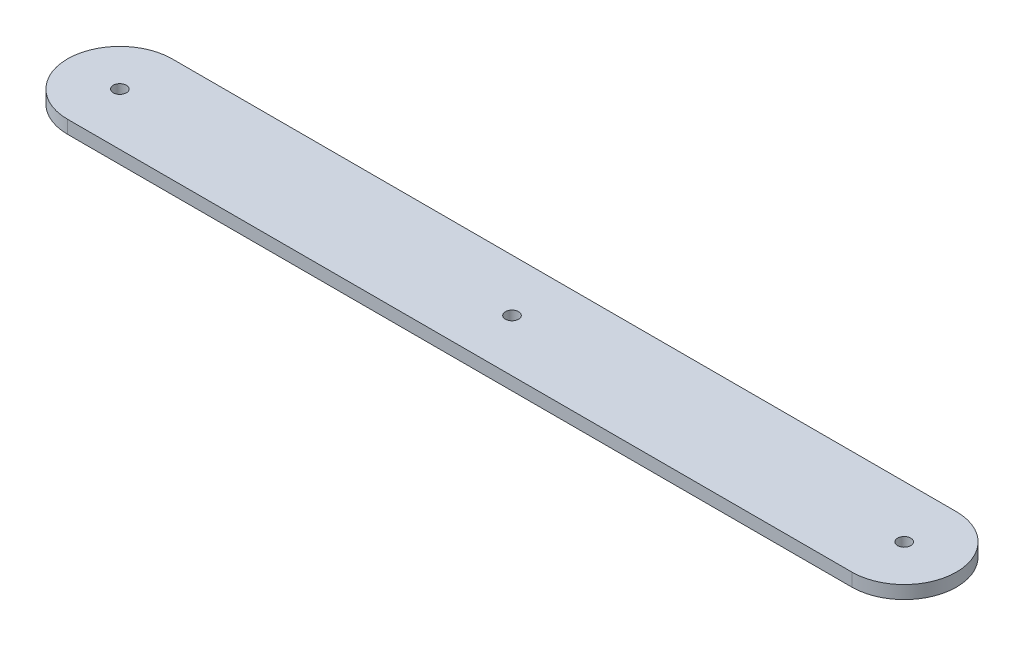
from build123d import *

# Parameters (mm, degrees)
BOSS_EXTRUDE1_DEPTH  = 3.175
M3_CLEARANCE_HOLE1_D = 3.2


with BuildPart() as part:
    # Sketch1 → Boss-Extrude1 (new body)
    with BuildSketch(Plane(origin=(0, 0, 0), x_dir=(1, 0, 0), z_dir=(0, 1, 0))):
        with BuildLine():
            Line((-95.25, 12.7), (95.25, 12.7))
            ThreePointArc((95.25, 12.7), (107.95, 0), (95.25, -12.7))
            Line((95.25, -12.7), (-95.25, -12.7))
            ThreePointArc((-95.25, -12.7), (-107.95, 0), (-95.25, 12.7))
        make_face()
    extrude(amount=BOSS_EXTRUDE1_DEPTH)

    # M3 Clearance Hole1 (through all)
    with Locations(Plane(origin=(0, 3.175, 0), x_dir=(1, 0, 0), z_dir=(0, 1, 0))):
        with Locations((-95.25, 0), (0, 0), (95.25, 0)):
            Hole(M3_CLEARANCE_HOLE1_D / 2)


solid = part.part
